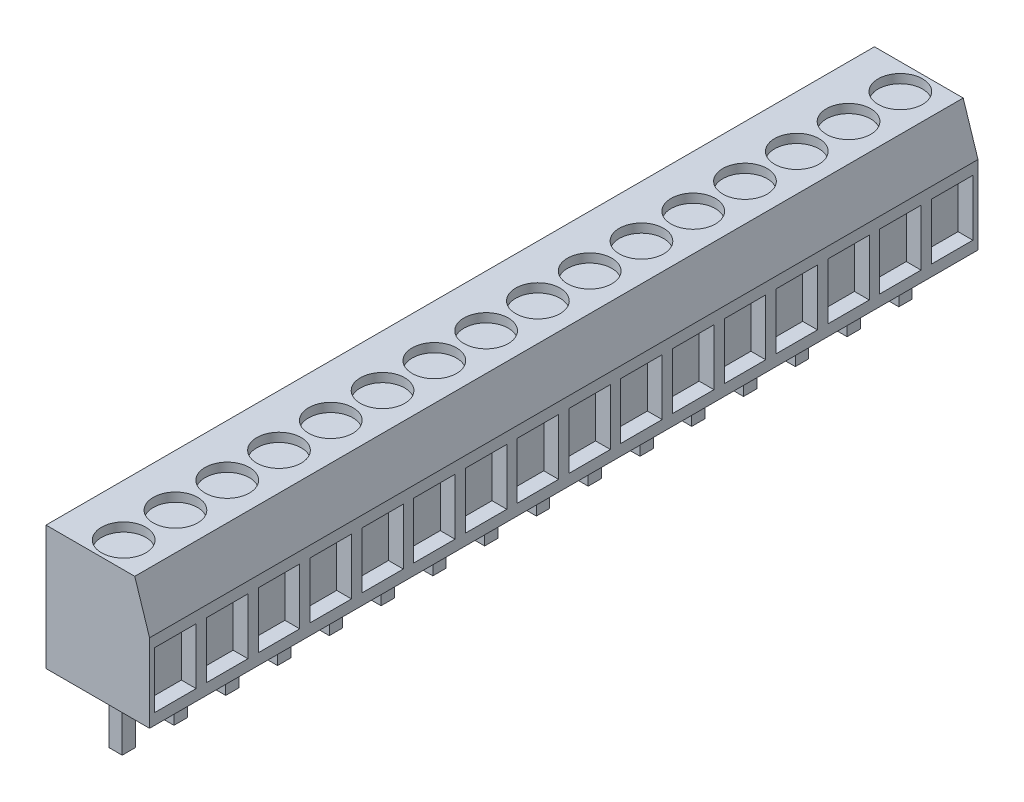
from build123d import *

# Parameters (mm, degrees)
BOSS_EXTRUDE1_DEPTH    = 56
SKETCH3_R              = 1.5
CUT_EXTRUDE1_DEPTH     = 0.6
SKETCH4_W              = 2.8
SKETCH4_H              = 3.8
CUT_EXTRUDE2_DEPTH     = 1
SKETCH5_W              = 0.9
SKETCH5_H              = 0.9
BOSS_EXTRUDE2_DEPTH    = 3.8
BOSS_EXTRUDE2_2_DEPTH  = 3.8
BOSS_EXTRUDE2_3_DEPTH  = 3.8
BOSS_EXTRUDE2_4_DEPTH  = 3.8
BOSS_EXTRUDE2_5_DEPTH  = 3.8
BOSS_EXTRUDE2_6_DEPTH  = 3.8
BOSS_EXTRUDE2_7_DEPTH  = 3.8
BOSS_EXTRUDE2_8_DEPTH  = 3.8
BOSS_EXTRUDE2_9_DEPTH  = 3.8
BOSS_EXTRUDE2_10_DEPTH = 3.8
BOSS_EXTRUDE2_11_DEPTH = 3.8
BOSS_EXTRUDE2_12_DEPTH = 3.8
BOSS_EXTRUDE2_13_DEPTH = 3.8
BOSS_EXTRUDE2_14_DEPTH = 3.8
BOSS_EXTRUDE2_15_DEPTH = 3.8
BOSS_EXTRUDE2_16_DEPTH = 3.8


with BuildPart() as part:
    # Sketch2 → Boss-Extrude1 (new body)
    with BuildSketch(Plane.XY):
        Polygon((0, 0), (0, 8.4), (6, 8.4), (7, 5.3), (7, 0), align=None)
    extrude(amount=-BOSS_EXTRUDE1_DEPTH)

    # Sketch3 → Cut-Extrude1 (cut)
    with BuildSketch(Plane(origin=(0, 8.4, 0), x_dir=(1, 0, 0), z_dir=(0, 1, 0))):
        with Locations((3.5, 1.75)):
            Circle(SKETCH3_R)
        with Locations((3.5, 5.25)):
            Circle(SKETCH3_R)
        with Locations((3.5, 8.75)):
            Circle(SKETCH3_R)
        with Locations((3.5, 12.25)):
            Circle(SKETCH3_R)
        with Locations((3.5, 15.75)):
            Circle(SKETCH3_R)
        with Locations((3.5, 19.25)):
            Circle(SKETCH3_R)
        with Locations((3.5, 22.75)):
            Circle(SKETCH3_R)
        with Locations((3.5, 26.25)):
            Circle(SKETCH3_R)
        with Locations((3.5, 29.75)):
            Circle(SKETCH3_R)
        with Locations((3.5, 33.25)):
            Circle(SKETCH3_R)
        with Locations((3.5, 36.75)):
            Circle(SKETCH3_R)
        with Locations((3.5, 40.25)):
            Circle(SKETCH3_R)
        with Locations((3.5, 43.75)):
            Circle(SKETCH3_R)
        with Locations((3.5, 47.25)):
            Circle(SKETCH3_R)
        with Locations((3.5, 50.75)):
            Circle(SKETCH3_R)
        with Locations((3.5, 54.25)):
            Circle(SKETCH3_R)
    extrude(amount=-CUT_EXTRUDE1_DEPTH, mode=Mode.SUBTRACT)

    # Sketch4 → Cut-Extrude2 (cut)
    with BuildSketch(Plane(origin=(7, 0, 0), x_dir=(0, 0, -1), z_dir=(1, 0, 0))):
        with Locations((5.25, 2.65)):
            Rectangle(SKETCH4_W, SKETCH4_H)
        with Locations((1.75, 2.65)):
            Rectangle(SKETCH4_W, SKETCH4_H)
        with Locations((8.75, 2.65)):
            Rectangle(SKETCH4_W, SKETCH4_H)
        with Locations((12.25, 2.65)):
            Rectangle(SKETCH4_W, SKETCH4_H)
        with Locations((15.75, 2.65)):
            Rectangle(SKETCH4_W, SKETCH4_H)
        with Locations((19.25, 2.65)):
            Rectangle(SKETCH4_W, SKETCH4_H)
        with Locations((22.75, 2.65)):
            Rectangle(SKETCH4_W, SKETCH4_H)
        with Locations((26.25, 2.65)):
            Rectangle(SKETCH4_W, SKETCH4_H)
        with Locations((29.75, 2.65)):
            Rectangle(SKETCH4_W, SKETCH4_H)
        with Locations((33.25, 2.65)):
            Rectangle(SKETCH4_W, SKETCH4_H)
        with Locations((36.75, 2.65)):
            Rectangle(SKETCH4_W, SKETCH4_H)
        with Locations((40.25, 2.65)):
            Rectangle(SKETCH4_W, SKETCH4_H)
        with Locations((43.75, 2.65)):
            Rectangle(SKETCH4_W, SKETCH4_H)
        with Locations((47.25, 2.65)):
            Rectangle(SKETCH4_W, SKETCH4_H)
        with Locations((50.75, 2.65)):
            Rectangle(SKETCH4_W, SKETCH4_H)
        with Locations((54.25, 2.65)):
            Rectangle(SKETCH4_W, SKETCH4_H)
    extrude(amount=-CUT_EXTRUDE2_DEPTH, mode=Mode.SUBTRACT)


with BuildPart() as body_2:
    # Sketch5 → Boss-Extrude2 (new body)
    with BuildSketch(Plane.XZ):
        with Locations((3.4, -1.75)):
            Rectangle(SKETCH5_W, SKETCH5_H)
    extrude(amount=BOSS_EXTRUDE2_DEPTH)


with BuildPart() as body_3:
    # Sketch5 → Boss-Extrude2 2 (new body)
    with BuildSketch(Plane.XZ):
        with Locations((3.4, -5.25)):
            Rectangle(SKETCH5_W, SKETCH5_H)
    extrude(amount=BOSS_EXTRUDE2_2_DEPTH)


with BuildPart() as body_4:
    # Sketch5 → Boss-Extrude2 3 (new body)
    with BuildSketch(Plane.XZ):
        with Locations((3.4, -8.75)):
            Rectangle(SKETCH5_W, SKETCH5_H)
    extrude(amount=BOSS_EXTRUDE2_3_DEPTH)


with BuildPart() as body_5:
    # Sketch5 → Boss-Extrude2 4 (new body)
    with BuildSketch(Plane.XZ):
        with Locations((3.4, -12.25)):
            Rectangle(SKETCH5_W, SKETCH5_H)
    extrude(amount=BOSS_EXTRUDE2_4_DEPTH)


with BuildPart() as body_6:
    # Sketch5 → Boss-Extrude2 5 (new body)
    with BuildSketch(Plane.XZ):
        with Locations((3.4, -15.75)):
            Rectangle(SKETCH5_W, SKETCH5_H)
    extrude(amount=BOSS_EXTRUDE2_5_DEPTH)


with BuildPart() as body_7:
    # Sketch5 → Boss-Extrude2 6 (new body)
    with BuildSketch(Plane.XZ):
        with Locations((3.4, -19.25)):
            Rectangle(SKETCH5_W, SKETCH5_H)
    extrude(amount=BOSS_EXTRUDE2_6_DEPTH)


with BuildPart() as body_8:
    # Sketch5 → Boss-Extrude2 7 (new body)
    with BuildSketch(Plane.XZ):
        with Locations((3.4, -22.75)):
            Rectangle(SKETCH5_W, SKETCH5_H)
    extrude(amount=BOSS_EXTRUDE2_7_DEPTH)


with BuildPart() as body_9:
    # Sketch5 → Boss-Extrude2 8 (new body)
    with BuildSketch(Plane.XZ):
        with Locations((3.4, -26.25)):
            Rectangle(SKETCH5_W, SKETCH5_H)
    extrude(amount=BOSS_EXTRUDE2_8_DEPTH)


with BuildPart() as body_10:
    # Sketch5 → Boss-Extrude2 9 (new body)
    with BuildSketch(Plane.XZ):
        with Locations((3.4, -29.75)):
            Rectangle(SKETCH5_W, SKETCH5_H)
    extrude(amount=BOSS_EXTRUDE2_9_DEPTH)


with BuildPart() as body_11:
    # Sketch5 → Boss-Extrude2 10 (new body)
    with BuildSketch(Plane.XZ):
        with Locations((3.4, -33.25)):
            Rectangle(SKETCH5_W, SKETCH5_H)
    extrude(amount=BOSS_EXTRUDE2_10_DEPTH)


with BuildPart() as body_12:
    # Sketch5 → Boss-Extrude2 11 (new body)
    with BuildSketch(Plane.XZ):
        with Locations((3.4, -36.75)):
            Rectangle(SKETCH5_W, SKETCH5_H)
    extrude(amount=BOSS_EXTRUDE2_11_DEPTH)


with BuildPart() as body_13:
    # Sketch5 → Boss-Extrude2 12 (new body)
    with BuildSketch(Plane.XZ):
        with Locations((3.4, -40.25)):
            Rectangle(SKETCH5_W, SKETCH5_H)
    extrude(amount=BOSS_EXTRUDE2_12_DEPTH)


with BuildPart() as body_14:
    # Sketch5 → Boss-Extrude2 13 (new body)
    with BuildSketch(Plane.XZ):
        with Locations((3.4, -43.75)):
            Rectangle(SKETCH5_W, SKETCH5_H)
    extrude(amount=BOSS_EXTRUDE2_13_DEPTH)


with BuildPart() as body_15:
    # Sketch5 → Boss-Extrude2 14 (new body)
    with BuildSketch(Plane.XZ):
        with Locations((3.4, -47.25)):
            Rectangle(SKETCH5_W, SKETCH5_H)
    extrude(amount=BOSS_EXTRUDE2_14_DEPTH)


with BuildPart() as body_16:
    # Sketch5 → Boss-Extrude2 15 (new body)
    with BuildSketch(Plane.XZ):
        with Locations((3.4, -50.75)):
            Rectangle(SKETCH5_W, SKETCH5_H)
    extrude(amount=BOSS_EXTRUDE2_15_DEPTH)


with BuildPart() as body_17:
    # Sketch5 → Boss-Extrude2 16 (new body)
    with BuildSketch(Plane.XZ):
        with Locations((3.4, -54.25)):
            Rectangle(SKETCH5_W, SKETCH5_H)
    extrude(amount=BOSS_EXTRUDE2_16_DEPTH)


solid = Compound([part.part, body_2.part, body_3.part, body_4.part, body_5.part, body_6.part, body_7.part, body_8.part, body_9.part, body_10.part, body_11.part, body_12.part, body_13.part, body_14.part, body_15.part, body_16.part, body_17.part])
